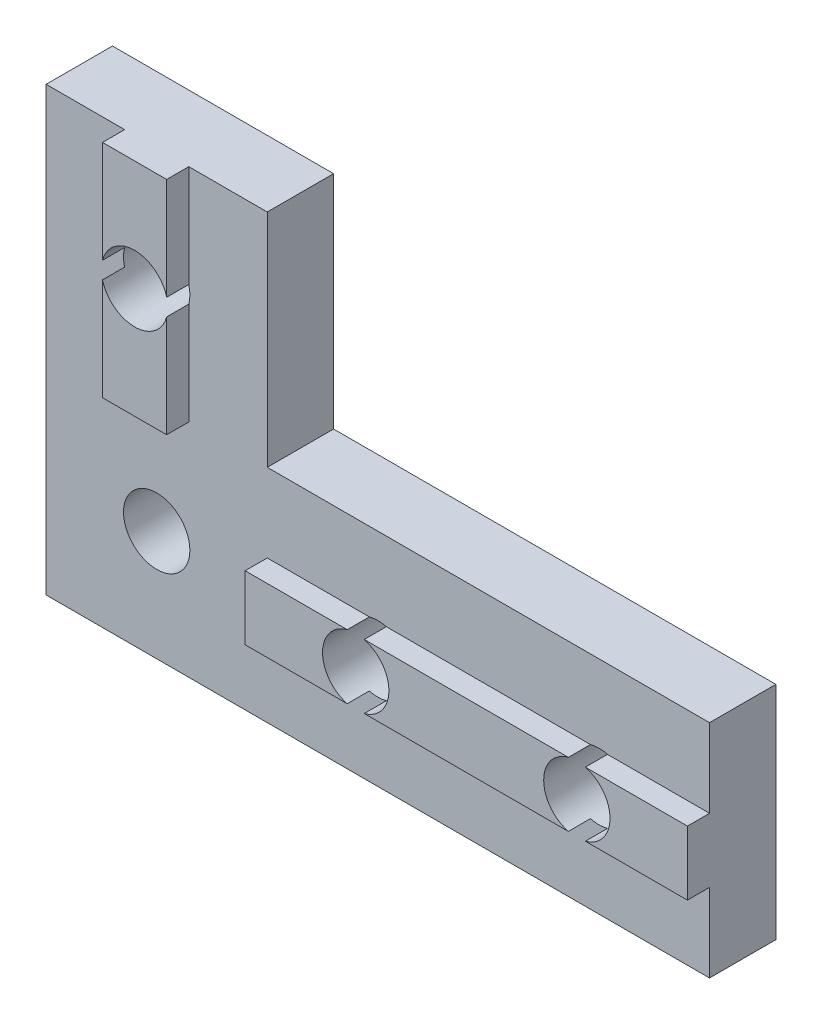
from build123d import *

# Parameters (mm, degrees)
BOSS_EXTRU_1_DEPTH      = 3
ESQUISSE2_W             = 2.9
ESQUISSE2_H             = 10
ESQUISSE2_W_2           = 20
ESQUISSE2_H_2           = 2.9
BOSS_EXTRU_2_DEPTH      = 1
ESQUISSE3_R             = 1.5
ENL_V_MAT_EXTRU_1_DEPTH = 5


with BuildPart() as part:
    # Esquisse1 → Boss.-Extru.1 (new body)
    with BuildSketch(Plane.XY):
        Polygon((0, 0), (30, 0), (30, 10), (10, 10), (10, 20), (0, 20), align=None)
    extrude(amount=BOSS_EXTRU_1_DEPTH)

    # Esquisse2 → Boss.-Extru.2 (add)
    with BuildSketch(Plane.XY.offset(3)):
        with Locations((5, 15)):
            Rectangle(ESQUISSE2_W, ESQUISSE2_H)
        with Locations((20, 5)):
            Rectangle(ESQUISSE2_W_2, ESQUISSE2_H_2)
    extrude(amount=BOSS_EXTRU_2_DEPTH)

    # Esquisse3 → Enlèv. mat.-Extru.1 (cut, through all)
    with BuildSketch(Plane(origin=(0, 0, 0), x_dir=(-1, 0, 0), z_dir=(0, 0, -1))):
        with Locations((-25, 5)):
            Circle(ESQUISSE3_R)
        with Locations((-15, 5)):
            Circle(ESQUISSE3_R)
        with Locations((-5, 15)):
            Circle(ESQUISSE3_R)
        with Locations((-5, 5)):
            Circle(ESQUISSE3_R)
    extrude(amount=-ENL_V_MAT_EXTRU_1_DEPTH, mode=Mode.SUBTRACT)


solid = part.part
